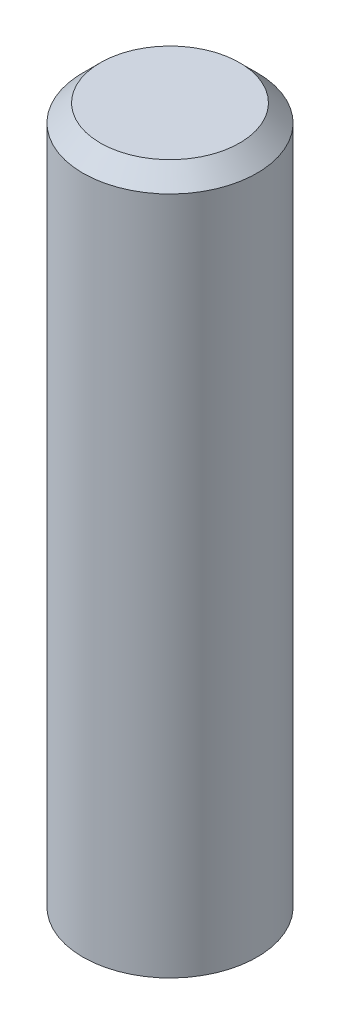
from build123d import *

# Parameters (mm, degrees)
SCHIZZO1_R                   = 0.5
ESTRUSIONE_ESTRUSIONE1_DEPTH = 2
SMUSSO1_SIZE                 = 0.1


with BuildPart() as part:
    # Schizzo1 → Estrusione-Estrusione1 (new body, symmetric)
    with BuildSketch(Plane(origin=(0, 0, 0), x_dir=(1, 0, 0), z_dir=(0, 1, 0))):
        Circle(SCHIZZO1_R)
    extrude(amount=ESTRUSIONE_ESTRUSIONE1_DEPTH, both=True)

    # Smusso1
    smusso1_edges = [part.edges().sort_by_distance(p)[0] for p in [
        (-0.5, 2, 0),
    ]]
    chamfer(smusso1_edges, length=SMUSSO1_SIZE)


solid = part.part
